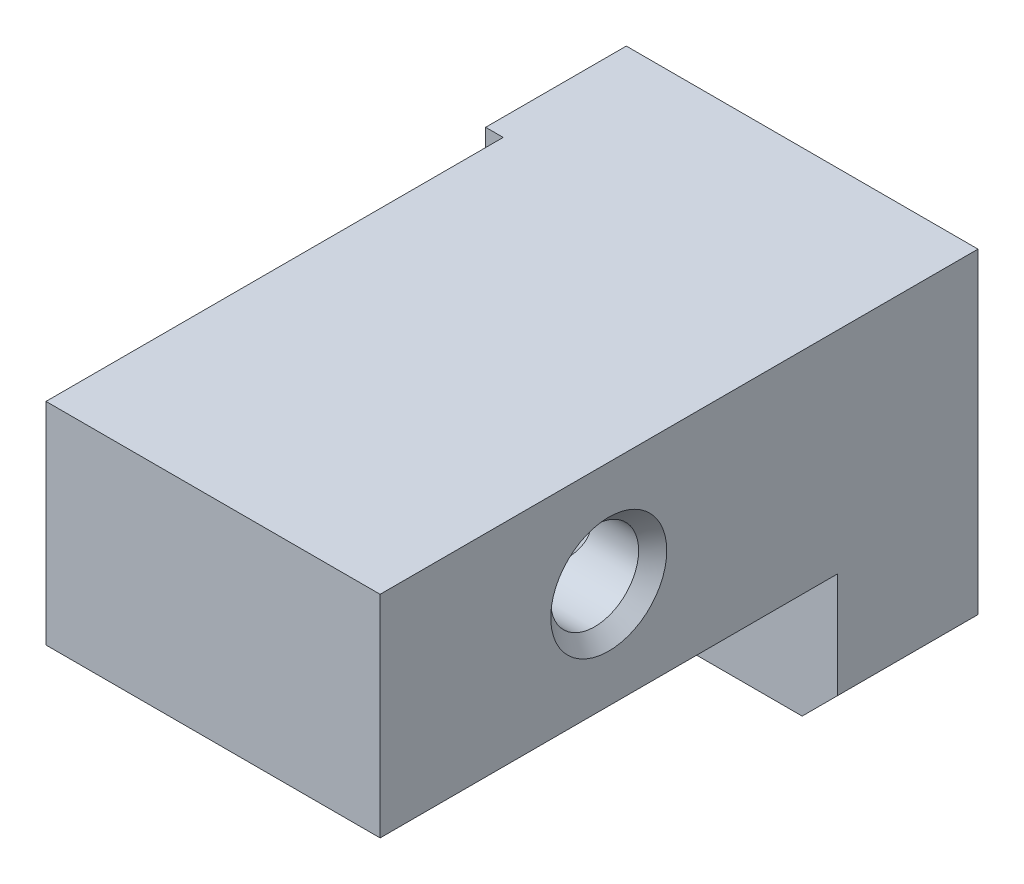
from build123d import *

# Parameters (mm, degrees)
SKETCH_1_W                  = 10
SKETCH_1_H                  = 10
EXTRUDE_1_DEPTH             = 17
CUT_EXTRUDE_1_DEPTH         = 13
HOLE_WIZARD_M32_D           = 2.5
HOLE_WIZARD_M32_DEPTH       = 10.5
HOLE_WIZARD_M32_CSINK_D     = 3.3
HOLE_WIZARD_M32_CSINK_ANGLE = 90
HOLE_WIZARD_M32_TIP         = 0.751075774
CHAMFER_1_SIZE              = 1


with BuildPart() as part:
    # Эскиз1 → Бобышка-Вытянуть1 (new body)
    with BuildSketch(Plane.XY):
        with Locations((5, 5)):
            Rectangle(SKETCH_1_W, SKETCH_1_H)
    extrude(amount=EXTRUDE_1_DEPTH)

    # Эскиз7 → Вырез-Вытянуть1 (cut)
    with BuildSketch(Plane.XY.offset(17)):
        Polygon((0.5, 4), (0.5, 10), (0, 10), (0, 0), (10, 0), (10, 4), align=None)
    extrude(amount=-CUT_EXTRUDE_1_DEPTH, mode=Mode.SUBTRACT)

    # Эскиз3 → Отверстие обработанное метчиком M31 (revolve, cut)
    with BuildSketch(Plane(origin=(10, 7, 10.5), x_dir=(0, 0, -1), z_dir=(0, 1, 0))):
        Polygon((0, 0), (0, 9.5), (1.65, 9.5), (1.25, 9.1), (1.25, 0.4), (1.65, 0), align=None)
    revolve(axis=Axis((16.35, 7, 10.5), (-1, 0, 0)), mode=Mode.SUBTRACT)

    # Отверстие обработанное метчиком M32
    with Locations(Plane(origin=(0, 0, 0), x_dir=(-1, 0, 0), z_dir=(0, 0, -1))):
        with Locations((-3, 3), (-7, 7)):
            CounterSinkHole(HOLE_WIZARD_M32_D / 2, HOLE_WIZARD_M32_CSINK_D / 2, depth=HOLE_WIZARD_M32_DEPTH, counter_sink_angle=HOLE_WIZARD_M32_CSINK_ANGLE)
            with Locations((0, 0, -(HOLE_WIZARD_M32_DEPTH + HOLE_WIZARD_M32_TIP / 2))):  # 118° drill point
                Cone(0, HOLE_WIZARD_M32_D / 2, HOLE_WIZARD_M32_TIP, mode=Mode.SUBTRACT)

    # Фаска1
    chamfer_1_edges = [part.edges().sort_by_distance(p)[0] for p in [
        (10, 0, 2),
    ]]
    chamfer(chamfer_1_edges, length=CHAMFER_1_SIZE)


solid = part.part
